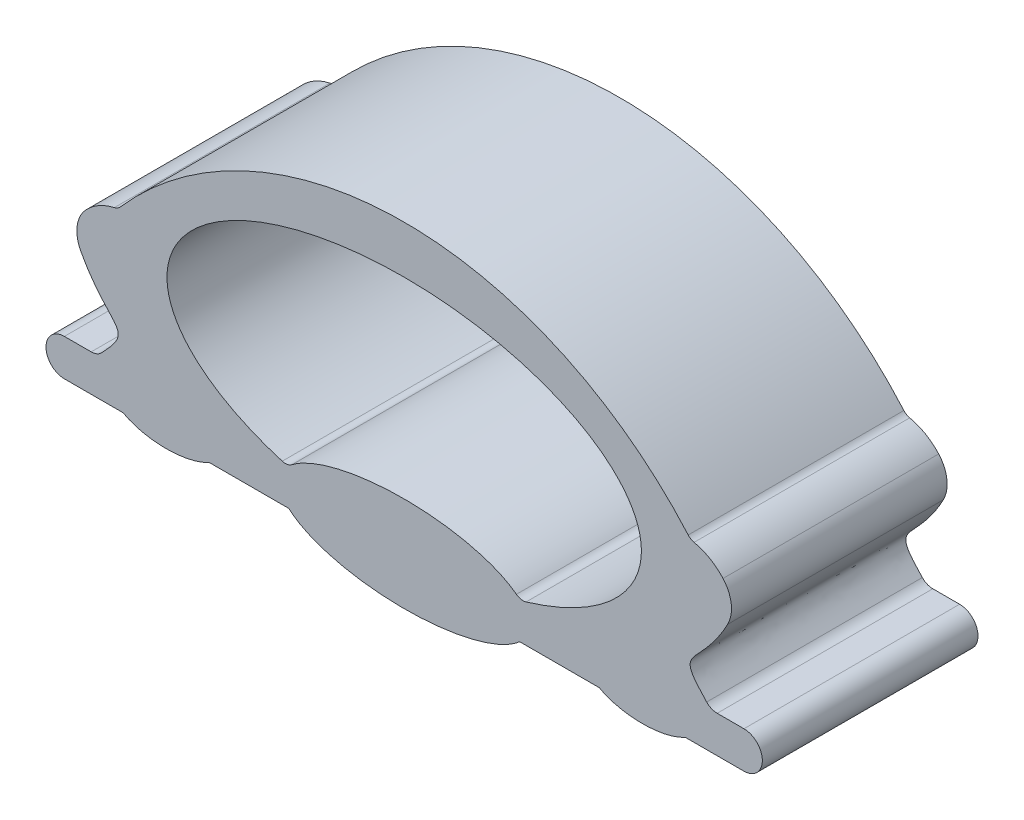
from build123d import *

# Parameters (mm, degrees)
SALIENTE_EXTRUIR2_DEPTH = 1


with BuildPart() as part:
    # Croquis2 → Saliente-Extruir2 (new body)
    with BuildSketch(Plane.XY):
        with BuildLine():
            Line((1.575601287, 0.305798808), (1.451356133, 0.305798808))
            ThreePointArc((1.451356133, 0.305798808), (1.42488117, 0.311210102), (1.402652914, 0.326575985))
            add(Edge.make_bspline(
                [(1.402652914, 0.326575985), (1.360130432, 0.370928794), (1.273091339, 0.474573616), (1.405822435, 0.509874509), (1.5, 0.687275792)],
                knots=[0.042799464, 0.042799464, 0.042799464, 0.042799464, 0.330664192, 1, 1, 1, 1], degree=3))
            ThreePointArc((1.5, 0.687275792), (1.516652539, 0.777416177), (1.478603287, 0.860811923))
            ThreePointArc((1.478603287, 0.860811923), (1.417548585, 0.910292451), (1.344234138, 0.938594237))
            ThreePointArc((1.344234138, 0.938594237), (1.329383947, 0.944391303), (1.317113195, 0.954567884))
            ThreePointArc((1.317113195, 0.954567884), (0, 1.552634988), (-1.317113195, 0.954567884))
            ThreePointArc((-1.317113195, 0.954567884), (-1.329383947, 0.944391303), (-1.344234138, 0.938594237))
            ThreePointArc((-1.344234138, 0.938594237), (-1.417548585, 0.910292451), (-1.478603287, 0.860811923))
            ThreePointArc((-1.478603287, 0.860811923), (-1.516652539, 0.777416177), (-1.5, 0.687275792))
            add(Edge.make_bspline(
                [(-1.402652914, 0.326575985), (-1.360130432, 0.370928794), (-1.273091339, 0.474573616), (-1.405822435, 0.509874509), (-1.5, 0.687275792)],
                knots=[0.042799464, 0.042799464, 0.042799464, 0.042799464, 0.330664192, 1, 1, 1, 1], degree=3))
            ThreePointArc((-1.402652914, 0.326575985), (-1.42488117, 0.311210102), (-1.451356133, 0.305798808))
            Line((-1.451356133, 0.305798808), (-1.575601287, 0.305798808))
            ThreePointArc((-1.575601287, 0.305798808), (-1.660882273, 0.220517823), (-1.575601287, 0.135236837))
            Line((-1.575601287, 0.135236837), (-1.303551262, 0.135236837))
            add(Edge.make_bspline(
                [(-1.303551262, 0.135236837), (-1.104083131, 0.023402954), (-0.904615, 0.135236837)],
                knots=[3.859431567, 3.859431567, 3.859431567, 5.565346393, 5.565346393, 5.565346393], degree=2, weights=[1, 0.657758416, 1]))
            Line((-0.904615, 0.135236837), (-0.535294671, 0.135236837))
            add(Edge.make_bspline(
                [(-0.535294671, 0.135236837), (0, -0.349692637), (0.535294671, 0.135236837)],
                knots=[3.538676333, 3.538676333, 3.538676333, 5.886101627, 5.886101627, 5.886101627], degree=2, weights=[1, 0.386730581, 1]))
            Line((0.535294671, 0.135236837), (0.904615, 0.135236837))
            add(Edge.make_bspline(
                [(0.904615, 0.135236837), (1.104083131, 0.023402954), (1.303551262, 0.135236837)],
                knots=[0.717838914, 0.717838914, 0.717838914, 2.42375374, 2.42375374, 2.42375374], degree=2, weights=[1, 0.657758416, 1]))
            Line((1.303551262, 0.135236837), (1.575601287, 0.135236837))
            ThreePointArc((1.575601287, 0.135236837), (1.660882273, 0.220517823), (1.575601287, 0.305798808))
        make_face()
        with BuildLine():
            ThreePointArc((-0.565338465, 0.309855878), (-0.541919045, 0.308582711), (-0.520495625, 0.318128772))
            add(Edge.make_bspline(
                [(0.520495625, 0.318128772), (0, 0.718700768), (-0.520495625, 0.318128772)],
                knots=[0.458545425, 0.458545425, 0.458545425, 2.683047228, 2.683047228, 2.683047228], degree=2, weights=[1, 0.442644262, 1]))
            ThreePointArc((0.520495625, 0.318128772), (0.541919045, 0.308582711), (0.565338465, 0.309855878))
            add(Edge.make_bspline(
                [(0.565338465, 0.309855878), (3.976320062, 1.331658914), (0, 1.331658914), (-3.976320062, 1.331658914), (-0.565338465, 0.309855878)],
                knots=[5.252165222, 5.252165222, 5.252165222, 7.853981634, 7.853981634, 10.455798046, 10.455798046, 10.455798046], degree=2, weights=[1, 0.266623609, 1, 0.266623609, 1]))
        make_face(mode=Mode.SUBTRACT)
    extrude(amount=-SALIENTE_EXTRUIR2_DEPTH)


solid = part.part
